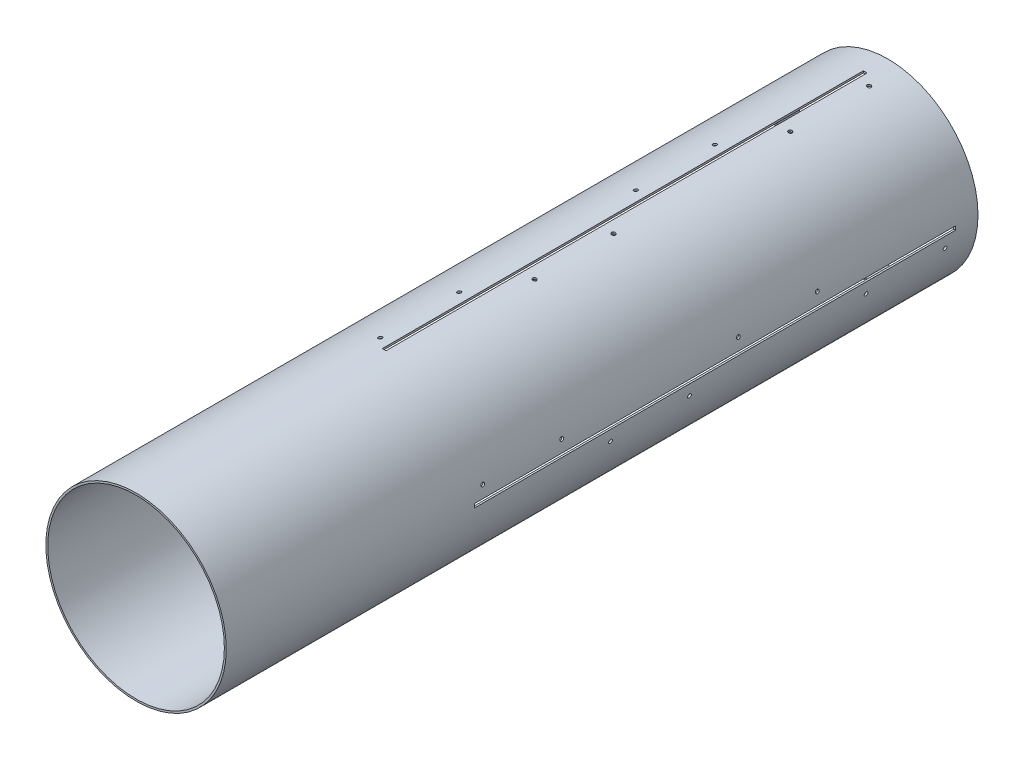
from build123d import *

# Parameters (mm, degrees)
SKETCH1_R           = 152.4
BOSS_EXTRUDE1_DEPTH = 1270
SKETCH2_R           = 149.225
CUT_EXTRUDE1_DEPTH  = 1270
SKETCH6_W           = 6.35
SKETCH6_H           = 812.8
CUT_EXTRUDE3_DEPTH  = 152.4
CIRPATTERN2_COUNT   = 4
CUT_EXTRUDE4_START  = 0.961836
SKETCH7_R           = 3.175
CUT_EXTRUDE4_DEPTH  = 3.243886
CUT_EXTRUDE5_START  = 0.961836
SKETCH8_R           = 3.175
CUT_EXTRUDE5_DEPTH  = 3.243886
CIRPATTERN3_COUNT   = 4


with BuildPart() as part:
    # Sketch1 → Boss-Extrude1 (new body)
    with BuildSketch(Plane.XY):
        Circle(SKETCH1_R)
    extrude(amount=BOSS_EXTRUDE1_DEPTH)

    # Sketch2 → Cut-Extrude1 (cut)
    with BuildSketch(Plane.XY.offset(1270)):
        Circle(SKETCH2_R)
    extrude(amount=-CUT_EXTRUDE1_DEPTH, mode=Mode.SUBTRACT)

    # Sketch6 → Cut-Extrude3 (cut)
    with BuildSketch(Plane(origin=(0, 0, 0), x_dir=(1, 0, 0), z_dir=(0, 1, 0))):
        with Locations((0, -444.5)):
            Rectangle(SKETCH6_W, SKETCH6_H)
    cut_extrude3 = extrude(amount=-CUT_EXTRUDE3_DEPTH, mode=Mode.SUBTRACT)

    # CirPattern2: Cut-Extrude3 ×4 about axis
    cirpattern2_axis = Axis((0, 0, 0), (0, 0, 1))
    for i in range(1, CIRPATTERN2_COUNT):
        add(cut_extrude3.rotate(cirpattern2_axis, i * 360 / CIRPATTERN2_COUNT), mode=Mode.SUBTRACT)

    # Sketch7 → Cut-Extrude4 (cut)
    with BuildSketch(Plane(origin=(-20.367702071, 146.78799876, 850.9), x_dir=(0.990393205, 0.13827979, 0), z_dir=(-0.13827979, 0.990393205, 0)).offset(CUT_EXTRUDE4_START)):
        with Locations((-1.484470958, 149.225)):
            Circle(SKETCH7_R)
        with Locations((-1.484470958, 15.875)):
            Circle(SKETCH7_R)
        with Locations((-1.484470958, 447.675)):
            Circle(SKETCH7_R)
        with Locations((-1.484470958, 581.025)):
            Circle(SKETCH7_R)
    cut_extrude4 = extrude(amount=CUT_EXTRUDE4_DEPTH, mode=Mode.SUBTRACT)

    # Sketch8 → Cut-Extrude5 (cut)
    with BuildSketch(Plane(origin=(20.367702071, 146.78799876, 469.9), x_dir=(-0.990393205, 0.13827979, 0), z_dir=(0.13827979, 0.990393205, 0)).offset(CUT_EXTRUDE5_START)):
        with Locations((-1.484470958, -282.575)):
            Circle(SKETCH8_R)
        with Locations((-1.484470958, -415.925)):
            Circle(SKETCH8_R)
        with Locations((-1.484470958, 15.875)):
            Circle(SKETCH8_R)
        with Locations((-1.484470958, 149.225)):
            Circle(SKETCH8_R)
    cut_extrude5 = extrude(amount=CUT_EXTRUDE5_DEPTH, mode=Mode.SUBTRACT)

    # CirPattern3: Cut-Extrude4, Cut-Extrude5 ×4 about axis
    cirpattern3_axis = Axis((0, 0, 0), (0, 0, 1))
    for i in range(1, CIRPATTERN3_COUNT):
        add(cut_extrude4.rotate(cirpattern3_axis, i * 360 / CIRPATTERN3_COUNT), mode=Mode.SUBTRACT)
        add(cut_extrude5.rotate(cirpattern3_axis, i * 360 / CIRPATTERN3_COUNT), mode=Mode.SUBTRACT)


solid = part.part
